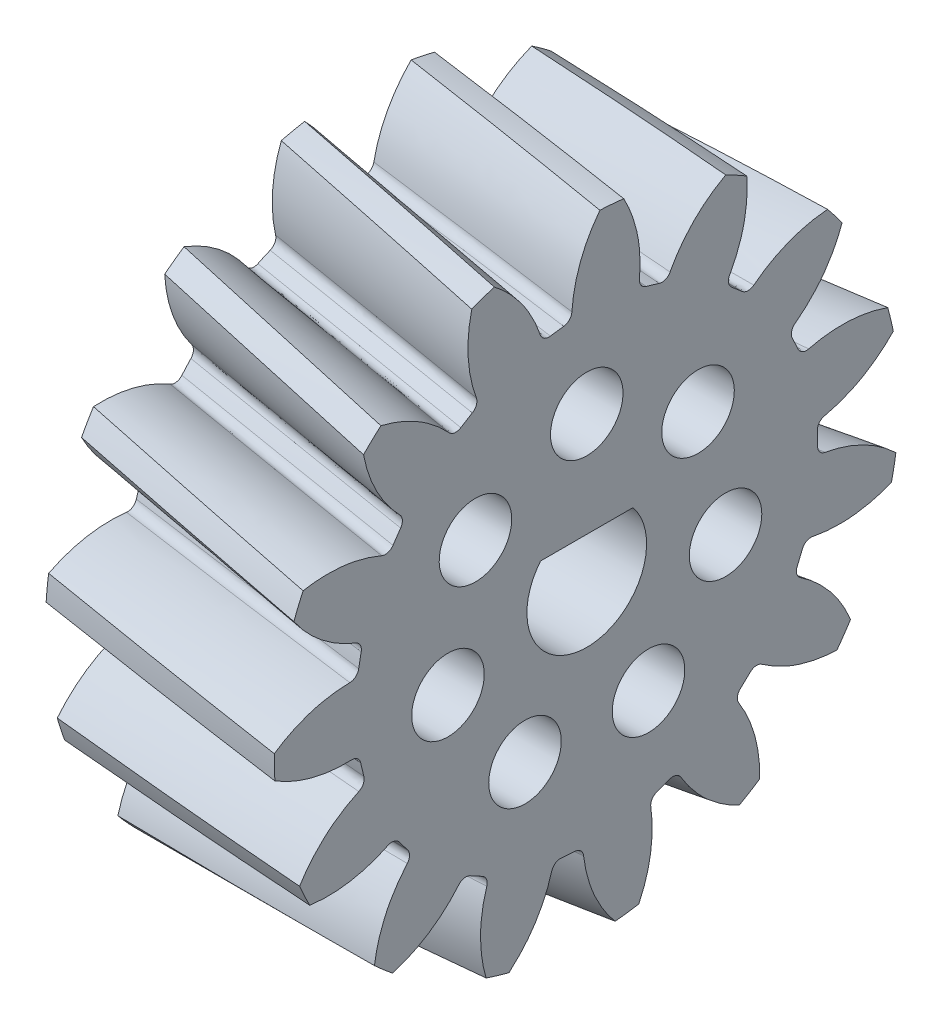
from build123d import *

# Parameters (mm, degrees)
BASPROSKE_W            = 6.31
BASPROSKE_H            = 8.615699589
TOOTHCUTRH_PITCH       = 307.009380255
TOOTHCUTRH_HEIGHT      = 6.31
TOOTHCUTRH_RADIUS      = 8.615699589
TOOTHCUTRH_START_ANGLE = -90
TEETHCUTSRH_COUNT      = 15
BORSKE_R               = 1.65
BORE_DEPTH             = 62.5000025
D_SHAFT_DEPTH          = 6.31
HOLE_R                 = 1
HOLES_DEPTH            = 7.310000108
KREISMUSTER1_COUNT     = 7


with BuildPart() as part:
    # BasProSke → Base-Revolve (revolve)
    with BuildSketch(Plane(origin=(0, 0, 0), x_dir=(1, 0, 0), z_dir=(0, 1, 0))):
        with Locations((3.155, 4.307849795)):
            Rectangle(BASPROSKE_W, BASPROSKE_H)
    revolve(axis=Axis((-10, 0, 0), (1, 0, 0)))

    # ToothCutRH: sweep along a helix
    with BuildLine() as toothcutrh_path:
        add(Helix(TOOTHCUTRH_PITCH, TOOTHCUTRH_HEIGHT, TOOTHCUTRH_RADIUS, center=(0, 0, 0), direction=(1, 0, 0), mode=Mode.PRIVATE).rotate(Axis((0, 0, 0), (1, 0, 0)), TOOTHCUTRH_START_ANGLE))
    # TooCutSkeRH → ToothCutRH (sweep, cut)
    with BuildSketch(Plane(origin=(0, 0, 0), x_dir=(0, 0, -1), z_dir=(1, 0, 0))):
        with BuildLine():
            ThreePointArc((0.185812052, 6.362987124), (0, 6.365699589), (-0.185812052, 6.362987124))
            ThreePointArc((-0.185812052, 6.362987124), (-0.34961482, 6.417624717), (-0.439361781, 6.565144535))
            ThreePointArc((-0.439361781, 6.565144535), (-0.889712762, 7.745083637), (-1.70623922, 8.708596394))
            ThreePointArc((-1.70623922, 8.708596394), (0, 8.874170577), (1.70623922, 8.708596394))
            ThreePointArc((1.70623922, 8.708596394), (0.889712762, 7.745083637), (0.439361781, 6.565144535))
            ThreePointArc((0.439361781, 6.565144535), (0.34961482, 6.417624717), (0.185812052, 6.362987124))
        make_face()
    toothcutrh = sweep(path=toothcutrh_path.line, is_frenet=True, mode=Mode.SUBTRACT)

    # TeethCutsRH: ToothCutRH ×15 about axis
    teethcutsrh_axis = Axis((-10, 0, 0), (1, 0, 0))
    for i in range(1, TEETHCUTSRH_COUNT):
        add(toothcutrh.rotate(teethcutsrh_axis, i * 360 / TEETHCUTSRH_COUNT), mode=Mode.SUBTRACT)

    # BorSke → Bore (cut, symmetric)
    with BuildSketch(Plane(origin=(0, 0, 0), x_dir=(0, 0, -1), z_dir=(1, 0, 0))):
        Circle(BORSKE_R)
    extrude(amount=BORE_DEPTH, both=True, mode=Mode.SUBTRACT)

    # dshaft → D-Shaft (add)
    with BuildSketch(Plane.ZY):
        with BuildLine():
            Line((-1.272792206, 1.05), (1.272792206, 1.05))
            ThreePointArc((1.272792206, 1.05), (0, 1.65), (-1.272792206, 1.05))
        make_face()
    extrude(amount=-D_SHAFT_DEPTH)

    # hole → holes (cut, through all)
    with BuildSketch(Plane.ZY):
        with Locations((0, 3.925080943)):
            Circle(HOLE_R)
    holes = extrude(amount=-HOLES_DEPTH, mode=Mode.SUBTRACT)

    # Kreismuster1: holes ×7 about axis
    kreismuster1_axis = Axis((0, 0, 0), (1, 0, 0))
    for i in range(1, KREISMUSTER1_COUNT):
        add(holes.rotate(kreismuster1_axis, i * 360 / KREISMUSTER1_COUNT), mode=Mode.SUBTRACT)


solid = part.part
